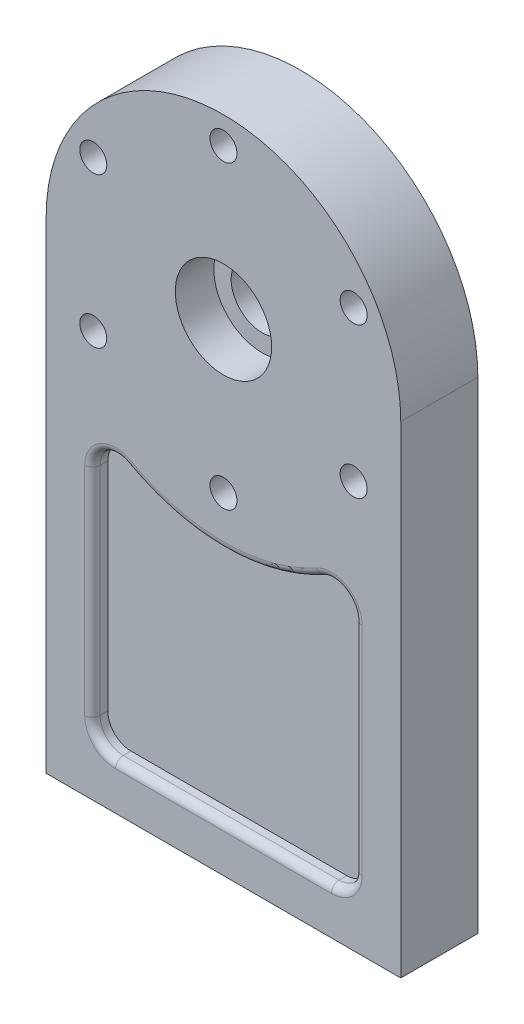
from build123d import *

# Parameters (mm, degrees)
SKETCH1_R                               = 8
BOSS_EXTRUDE1_DEPTH                     = 10
SKETCH2_R                               = 12.5
CUT_EXTRUDE1_DEPTH                      = 10
SKETCH3_R                               = 3.5
CUT_EXTRUDE2_DEPTH                      = 21
SKETCH4_R                               = 6
CUT_EXTRUDE3_DEPTH                      = 6
CUT_EXTRUDE4_DEPTH                      = 4
FILLET1_R                               = 2
TAP_DRILL_FOR_M10X1_25_TAP1_D           = 8.8
TAP_DRILL_FOR_M10X1_25_TAP1_DEPTH       = 13
TAP_DRILL_FOR_M10X1_25_TAP1_CSINK_D     = 8.85
TAP_DRILL_FOR_M10X1_25_TAP1_CSINK_ANGLE = 90
TAP_DRILL_FOR_M10X1_25_TAP1_TIP         = 2.643786724
FILLET1_OF_MIRROR4_R                    = 2


with BuildPart() as part:
    # Sketch1 → Boss-Extrude1 (new body, symmetric)
    with BuildSketch(Plane.XY):
        with BuildLine():
            Line((-46, 0), (-46, -125))
            Line((-46, -125), (46, -125))
            Line((46, -125), (46, 0))
            ThreePointArc((46, 0), (0, 46), (-46, 0))
        make_face()
        Circle(SKETCH1_R, mode=Mode.SUBTRACT)
    extrude(amount=BOSS_EXTRUDE1_DEPTH, both=True)

    # Sketch2 → Cut-Extrude1 (cut)
    with BuildSketch(Plane.XY.offset(10)):
        Circle(SKETCH2_R)
    extrude(amount=-CUT_EXTRUDE1_DEPTH, mode=Mode.SUBTRACT)

    # Sketch3 → Cut-Extrude2 (cut, through all)
    with BuildSketch(Plane.XY.offset(10)):
        with Locations((0, 39)):
            Circle(SKETCH3_R)
        with Locations((33.774990748, 19.5)):
            Circle(SKETCH3_R)
        with Locations((33.774990748, -19.5)):
            Circle(SKETCH3_R)
        with Locations((0, -39)):
            Circle(SKETCH3_R)
        with Locations((-33.774990748, -19.5)):
            Circle(SKETCH3_R)
        with Locations((-33.774990748, 19.5)):
            Circle(SKETCH3_R)
    extrude(amount=-CUT_EXTRUDE2_DEPTH, mode=Mode.SUBTRACT)

    # Sketch4 → Cut-Extrude3 (cut)
    with BuildSketch(Plane(origin=(0, 0, -10), x_dir=(-1, 0, 0), z_dir=(0, 0, -1))):
        with Locations((0, 39)):
            Circle(SKETCH4_R)
        with Locations((33.774990748, 19.5)):
            Circle(SKETCH4_R)
        with Locations((33.774990748, -19.5)):
            Circle(SKETCH4_R)
        with Locations((0, -39)):
            Circle(SKETCH4_R)
        with Locations((-33.774990748, -19.5)):
            Circle(SKETCH4_R)
        with Locations((-33.774990748, 19.5)):
            Circle(SKETCH4_R)
    extrude(amount=-CUT_EXTRUDE3_DEPTH, mode=Mode.SUBTRACT)

    # Sketch5 → Cut-Extrude4 (cut)
    with BuildSketch(Plane.XY.offset(10)):
        with BuildLine():
            Line((-34, -50.793700397), (-34, -107))
            ThreePointArc((-34, -107), (-32.242640687, -111.242640687), (-28, -113))
            Line((-28, -113), (28, -113))
            ThreePointArc((28, -113), (32.242640687, -111.242640687), (34, -107))
            Line((34, -107), (34, -50.793700397))
            ThreePointArc((34, -50.793700397), (31.051285766, -45.627497229), (25.103448276, -45.539179666))
            ThreePointArc((25.103448276, -45.539179666), (0, -52), (-25.103448276, -45.539179666))
            ThreePointArc((-25.103448276, -45.539179666), (-31.051285766, -45.627497229), (-34, -50.793700397))
        make_face()
    cut_extrude4 = extrude(amount=-CUT_EXTRUDE4_DEPTH, mode=Mode.SUBTRACT)

    # Fillet1
    fillet1_edges = [part.edges().sort_by_distance(p)[0] for p in [
        (32.242640687, -111.242640687, 10),
        (34, -78.896850198, 10),
        (31.051285766, -45.627497229, 10),
        (0, -52, 10),
        (-31.051285766, -45.627497229, 10),
        (-34, -78.896850198, 10),
        (-32.242640687, -111.242640687, 10),
        (0, -113, 10),
    ]]
    fillet(fillet1_edges, radius=FILLET1_R)

    # Tap Drill for M10x1.25 Tap1
    with Locations(Plane(origin=(0, -125, 0), x_dir=(-1, 0, 0), z_dir=(0, -1, 0))):
        with Locations((30, 0), (-30, 0)):
            CounterSinkHole(TAP_DRILL_FOR_M10X1_25_TAP1_D / 2, TAP_DRILL_FOR_M10X1_25_TAP1_CSINK_D / 2, depth=TAP_DRILL_FOR_M10X1_25_TAP1_DEPTH, counter_sink_angle=TAP_DRILL_FOR_M10X1_25_TAP1_CSINK_ANGLE)
            with Locations((0, 0, -(TAP_DRILL_FOR_M10X1_25_TAP1_DEPTH + TAP_DRILL_FOR_M10X1_25_TAP1_TIP / 2))):  # 118° drill point
                Cone(0, TAP_DRILL_FOR_M10X1_25_TAP1_D / 2, TAP_DRILL_FOR_M10X1_25_TAP1_TIP, mode=Mode.SUBTRACT)

    # Mirror4: Cut-Extrude4 across plane
    add(cut_extrude4.mirror(Plane.XY), mode=Mode.SUBTRACT)

    # Fillet1 of Mirror4
    fillet1_of_mirror4_edges = [part.edges().sort_by_distance(p)[0] for p in [
        (32.242640687, -111.242640687, -10),
        (34, -78.896850198, -10),
        (31.051285766, -45.627497229, -10),
        (0, -52, -10),
        (-31.051285766, -45.627497229, -10),
        (-34, -78.896850198, -10),
        (-32.242640687, -111.242640687, -10),
        (0, -113, -10),
    ]]
    fillet(fillet1_of_mirror4_edges, radius=FILLET1_OF_MIRROR4_R)


solid = part.part
